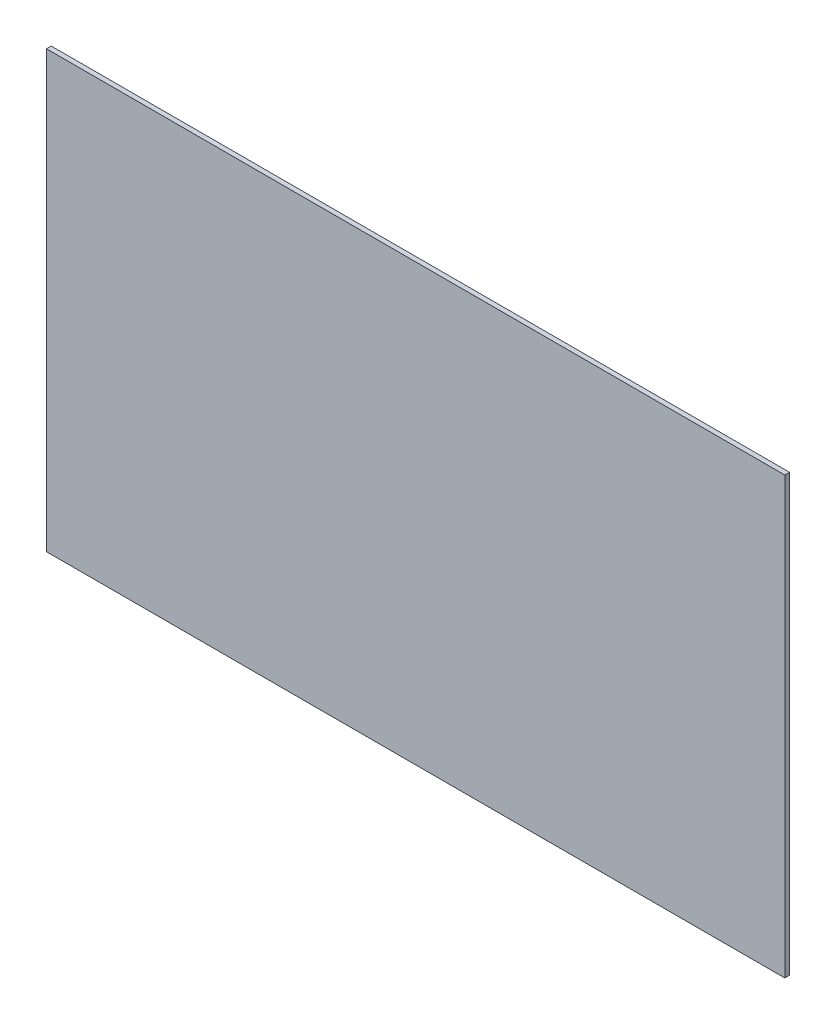
from build123d import *

# Parameters (mm, degrees)
ESQUISSE1_W        = 250
ESQUISSE1_H        = 147.5
BOSS_EXTRU_1_DEPTH = 1.6


with BuildPart() as part:
    # Esquisse1 → Boss.-Extru.1 (new body)
    with BuildSketch(Plane.XY):
        Rectangle(ESQUISSE1_W, ESQUISSE1_H)
    extrude(amount=BOSS_EXTRU_1_DEPTH)


solid = part.part
